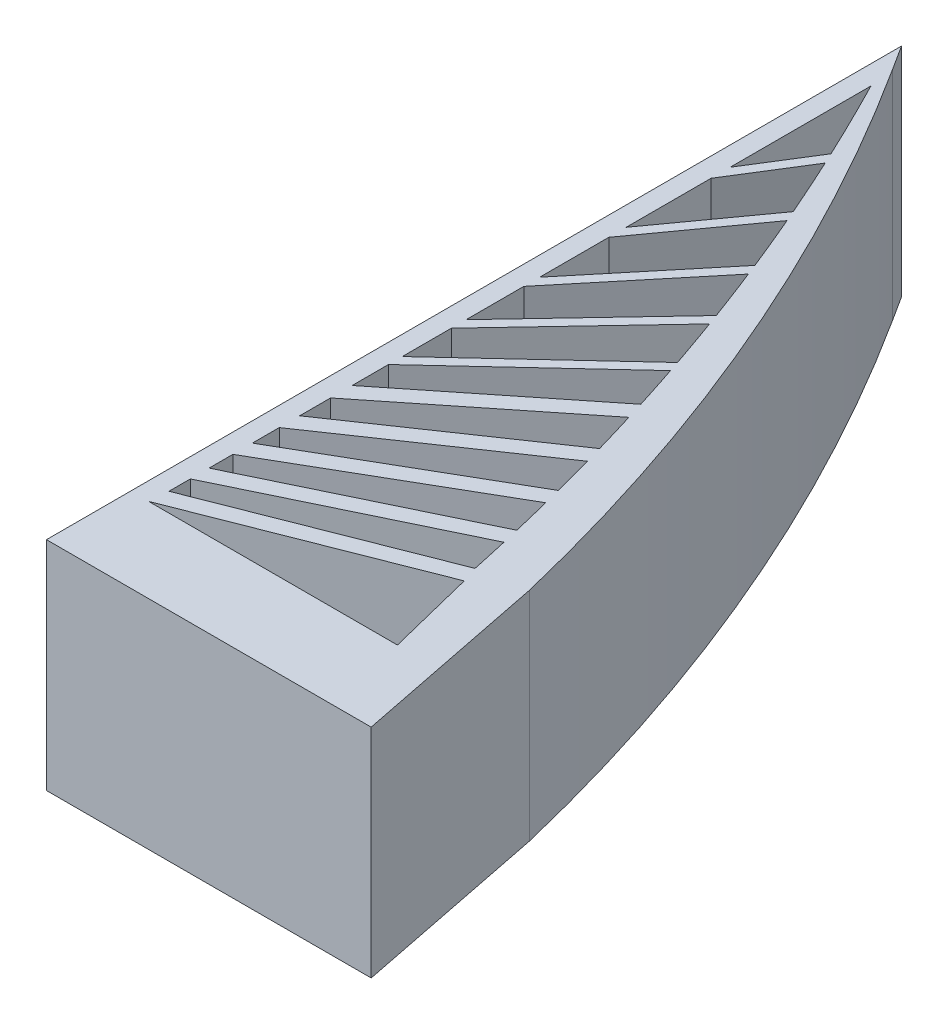
from build123d import *

# Parameters (mm, degrees)
BOSS_EXTRUDE1_DEPTH = 25.8


with BuildPart() as part:
    # Sketch1 → Boss-Extrude1 (new body)
    with BuildSketch(Plane.XZ.offset(25.8)):
        with BuildLine():
            Line((-0.494571956, -23.689779316), (-0.494571956, -23.589779316))
            Line((-0.494571956, -23.589779316), (-0.394571956, -23.589779316))
            Line((-0.394571956, -23.589779316), (33.993371563, -23.589779316))
            Line((33.993371563, -23.589779316), (38.063220374, -23.589779316))
            Line((38.063220374, -23.589779316), (37.29331502, -27.450677709))
            add(Edge.make_bspline(
                [(33.373472705, -47.107785962), (35.333393862, -37.279231836), (37.29331502, -27.450677709)],
                knots=[0, 0, 0, 1, 1, 1], degree=2))
            ThreePointArc((33.373472705, -47.107785962), (20.478962104, -86.002469597), (1.348099623, -122.238845235))
            Line((1.348099623, -122.238845235), (-0.494571956, -125.122735442))
            Line((-0.494571956, -125.122735442), (-0.494571956, -121.700417329))
            Line((-0.494571956, -121.700417329), (-0.494571956, -23.689779316))
        make_face()
        Polygon((1.636693568, -33.589779316), (31.180296724, -33.589779316), (28.552125449, -44.152877649), align=None, mode=Mode.SUBTRACT)
        with BuildLine():
            Line((1.8, -35.835600274), (27.903926427, -46.080219159))
            ThreePointArc((27.903926427, -46.080219159), (27.424243887, -48.283989571), (26.927669734, -50.484015362))
            Line((26.927669734, -50.484015362), (1.8, -38.383681926))
            Line((1.8, -38.383681926), (1.8, -35.835600274))
        make_face(mode=Mode.SUBTRACT)
        with BuildLine():
            Line((1.8, -40.603496686), (26.461878816, -52.479526576))
            ThreePointArc((26.461878816, -52.479526576), (25.912863392, -54.754715884), (25.345753049, -57.025462497))
            Line((25.345753049, -57.025462497), (1.8, -43.431924445))
            Line((1.8, -43.431924445), (1.8, -40.603496686))
        make_face(mode=Mode.SUBTRACT)
        with BuildLine():
            Line((1.8, -45.741299666), (24.827629624, -59.035712415))
            ThreePointArc((24.827629624, -59.035712415), (24.198120154, -61.402606851), (23.548915198, -63.764175052))
            Line((23.548915198, -63.764175052), (1.8, -48.936721812))
            Line((1.8, -48.936721812), (1.8, -45.741299666))
        make_face(mode=Mode.SUBTRACT)
        with BuildLine():
            Line((1.8, -51.35729301), (22.974243013, -65.792960045))
            ThreePointArc((22.974243013, -65.792960045), (22.250225593, -68.273323364), (21.504437212, -70.747227791))
            Line((21.504437212, -70.747227791), (1.8, -55.034267198))
            Line((1.8, -55.034267198), (1.8, -51.35729301))
        make_face(mode=Mode.SUBTRACT)
        with BuildLine():
            Line((1.8, -57.592312351), (20.868191148, -72.797909591))
            ThreePointArc((20.868191148, -72.797909591), (20.032066674, -75.415616602), (19.171511459, -78.02539415))
            Line((19.171511459, -78.02539415), (1.8, -61.907631839))
            Line((1.8, -61.907631839), (1.8, -57.592312351))
        make_face(mode=Mode.SUBTRACT)
        with BuildLine():
            Line((1.8, -63.544593475), (18.75085734, -79.272061417))
            ThreePointArc((18.75085734, -79.272061417), (17.733603559, -82.213523384), (16.685267787, -85.144051641))
            Line((16.685267787, -85.144051641), (1.8, -69.379364433))
            Line((1.8, -69.379364433), (1.8, -63.544593475))
        make_face(mode=Mode.SUBTRACT)
        with BuildLine():
            Line((1.8, -71.127270664), (16.223970717, -86.40340744))
            ThreePointArc((16.223970717, -86.40340744), (15.062552919, -89.498168213), (13.866413905, -92.579675475))
            Line((13.866413905, -92.579675475), (1.8, -77.977808183))
            Line((1.8, -77.977808183), (1.8, -71.127270664))
        make_face(mode=Mode.SUBTRACT)
        with BuildLine():
            Line((1.8, -79.861617911), (13.360943276, -93.851802636))
            ThreePointArc((13.360943276, -93.851802636), (12.031133738, -97.119012014), (10.66221999, -100.37003119))
            Line((10.66221999, -100.37003119), (1.8, -88.073893757))
            Line((1.8, -88.073893757), (1.8, -79.861617911))
        make_face(mode=Mode.SUBTRACT)
        with BuildLine():
            Line((1.8, -90.126243158), (10.108701369, -101.654385546))
            ThreePointArc((10.108701369, -101.654385546), (8.581699979, -105.113401186), (7.010340095, -108.552492716))
            Line((7.010340095, -108.552492716), (1.8, -100.212262217))
            Line((1.8, -100.212262217), (1.8, -90.126243158))
        make_face(mode=Mode.SUBTRACT)
        with BuildLine():
            Line((1.8, -102.47713769), (6.404592978, -109.847744231))
            ThreePointArc((6.404592978, -109.847744231), (4.143731804, -114.543136732), (1.8, -119.197717832))
            Line((1.8, -119.197717832), (1.8, -102.47713769))
        make_face(mode=Mode.SUBTRACT)
    extrude(amount=-BOSS_EXTRUDE1_DEPTH)


solid = part.part
